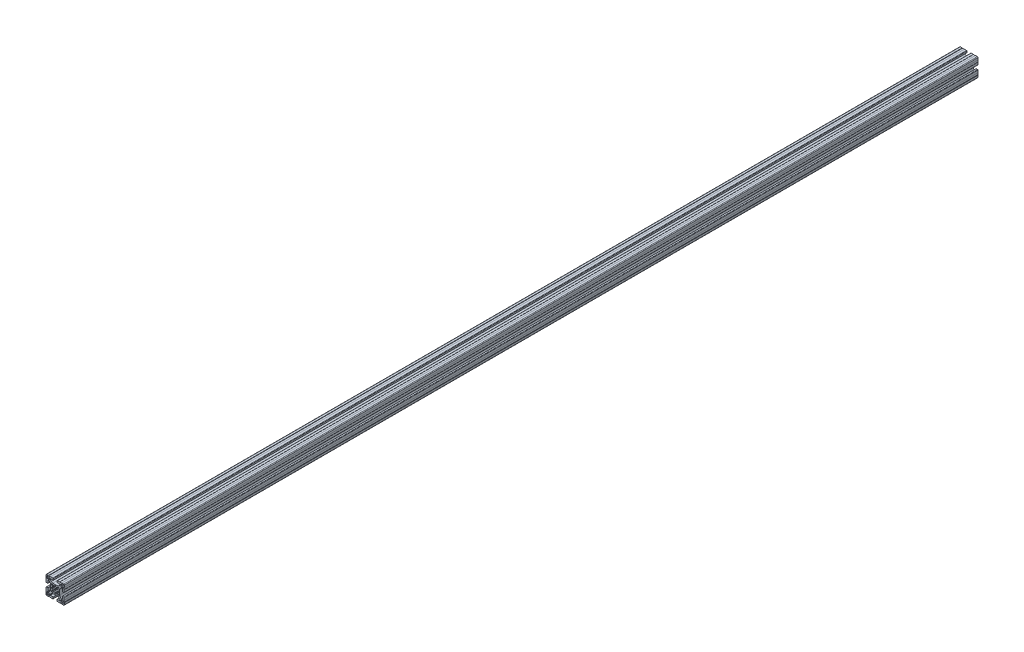
from build123d import *

# Parameters (mm, degrees)
RESSALTO_EXTRUS_O1_DEPTH = 1000


with BuildPart() as part:
    # Esboço1 → Ressalto-extrusão1 (new body, symmetric)
    with BuildSketch(Plane.XY):
        with BuildLine():
            Line((4.14998475, -18.79998475), (4.14998475, -15.899980918))
            ThreePointArc((4.14998475, -15.899980918), (4.179274222, -15.829270089), (4.249985176, -15.799980918))
            Line((4.249985176, -15.799980918), (10.499997871, -15.800007531))
            ThreePointArc((10.499997871, -15.800007531), (10.853552638, -15.653561674), (11, -15.300007531))
            Line((11, -15.300007531), (11, -14.449747468))
            ThreePointArc((11, -14.449747468), (10.885819299, -13.87572232), (10.560660172, -13.389087297))
            Line((10.560660172, -13.389087297), (8.636038969, -11.464466094))
            ThreePointArc((8.636038969, -11.464466094), (7.013922225, -10.380602337), (5.100505063, -10))
            Line((5.100505063, -10), (0, -10))
            Line((0, -10), (-5.100505063, -10))
            ThreePointArc((-5.100505063, -10), (-7.013922225, -10.380602337), (-8.636038969, -11.464466094))
            Line((-8.636038969, -11.464466094), (-10.560660172, -13.389087297))
            ThreePointArc((-10.560660172, -13.389087297), (-10.885819299, -13.87572232), (-11, -14.449747468))
            Line((-11, -14.449747468), (-11, -15.300007531))
            ThreePointArc((-11, -15.300007531), (-10.853552638, -15.653561674), (-10.499997871, -15.800007531))
            Line((-10.499997871, -15.800007531), (-4.249985176, -15.799980918))
            ThreePointArc((-4.249985176, -15.799980918), (-4.179274222, -15.829270089), (-4.14998475, -15.899980918))
            Line((-4.14998475, -15.899980918), (-4.14998475, -18.79998475))
            ThreePointArc((-4.14998475, -18.79998475), (-4.442876463, -19.507090026), (-5.149980492, -19.79998475))
            Line((-5.149980492, -19.79998475), (-9.79996495, -19.80000455))
            Line((-9.79996495, -19.80000455), (-9.99998475, -19.59998475))
            Line((-9.99998475, -19.59998475), (-13.99998475, -19.59998475))
            Line((-13.99998475, -19.59998475), (-14.40000475, -20.00000475))
            Line((-14.40000475, -20.00000475), (-18.50000475, -20.00000475))
            ThreePointArc((-18.50000475, -20.00000475), (-19.560664922, -19.560664922), (-20.00000475, -18.50000475))
            Line((-20.00000475, -18.50000475), (-20.00000475, -14.40000475))
            Line((-20.00000475, -14.40000475), (-19.59998475, -13.99998475))
            Line((-19.59998475, -13.99998475), (-19.59998475, -9.99998475))
            Line((-19.59998475, -9.99998475), (-19.800004551, -9.799964949))
            Line((-19.800004551, -9.799964949), (-19.799984751, -5.149980488))
            ThreePointArc((-19.799984751, -5.149980488), (-19.507090026, -4.442876459), (-18.79998475, -4.149984746))
            Line((-18.79998475, -4.149984746), (-15.899980918, -4.149984746))
            ThreePointArc((-15.899980918, -4.149984746), (-15.829270089, -4.179274218), (-15.799980918, -4.249985172))
            Line((-15.799980918, -4.249985172), (-15.800007532, -10.499997871))
            ThreePointArc((-15.800007532, -10.499997871), (-15.653561675, -10.853552638), (-15.300007532, -11))
            Line((-15.300007532, -11), (-14.449747468, -11))
            ThreePointArc((-14.449747468, -11), (-13.87572232, -10.885819298), (-13.389087297, -10.560660171))
            Line((-13.389087297, -10.560660171), (-11.464466094, -8.636038969))
            ThreePointArc((-11.464466094, -8.636038969), (-10.380602337, -7.013922225), (-10, -5.100505063))
            Line((-10, -5.100505063), (-10, 0))
            Line((-10, 0), (-10, 5.100505064))
            ThreePointArc((-10, 5.100505064), (-10.380602337, 7.013922225), (-11.464466094, 8.63603897))
            Line((-11.464466094, 8.63603897), (-13.389087297, 10.560660172))
            ThreePointArc((-13.389087297, 10.560660172), (-13.87572232, 10.885819299), (-14.449747468, 11))
            Line((-14.449747468, 11), (-15.300007532, 11))
            ThreePointArc((-15.300007532, 11), (-15.653561675, 10.853552638), (-15.800007532, 10.499997871))
            Line((-15.800007532, 10.499997871), (-15.799980918, 4.249985172))
            ThreePointArc((-15.799980918, 4.249985172), (-15.829270089, 4.179274219), (-15.899980918, 4.149984747))
            Line((-15.899980918, 4.149984747), (-18.79998475, 4.149984747))
            ThreePointArc((-18.79998475, 4.149984747), (-19.507090026, 4.44287646), (-19.799984751, 5.149980488))
            Line((-19.799984751, 5.149980488), (-19.800004551, 9.79996495))
            Line((-19.800004551, 9.79996495), (-19.59998475, 9.999984751))
            Line((-19.59998475, 9.999984751), (-19.59998475, 13.999984751))
            Line((-19.59998475, 13.999984751), (-20.00000475, 14.400004751))
            Line((-20.00000475, 14.400004751), (-20.00000475, 18.500004751))
            ThreePointArc((-20.00000475, 18.500004751), (-19.560664922, 19.560664922), (-18.50000475, 20.000004751))
            Line((-18.50000475, 20.000004751), (-14.40000475, 20.000004751))
            Line((-14.40000475, 20.000004751), (-13.99998475, 19.599984751))
            Line((-13.99998475, 19.599984751), (-9.99998475, 19.599984751))
            Line((-9.99998475, 19.599984751), (-9.79996495, 19.800004551))
            Line((-9.79996495, 19.800004551), (-5.149980492, 19.799984751))
            ThreePointArc((-5.149980492, 19.799984751), (-4.442876463, 19.507090026), (-4.14998475, 18.799984751))
            Line((-4.14998475, 18.799984751), (-4.14998475, 15.899980918))
            ThreePointArc((-4.14998475, 15.899980918), (-4.179274222, 15.82927009), (-4.249985176, 15.799980918))
            Line((-4.249985176, 15.799980918), (-10.499997871, 15.800007531))
            ThreePointArc((-10.499997871, 15.800007531), (-10.853552638, 15.653561675), (-11, 15.300007531))
            Line((-11, 15.300007531), (-11, 14.449747469))
            ThreePointArc((-11, 14.449747469), (-10.885819299, 13.87572232), (-10.560660172, 13.389087297))
            Line((-10.560660172, 13.389087297), (-8.636038969, 11.464466095))
            ThreePointArc((-8.636038969, 11.464466095), (-7.013922225, 10.380602338), (-5.100505063, 10.000000001))
            Line((-5.100505063, 10.000000001), (0, 10.000000001))
            Line((0, 10.000000001), (5.100505063, 10.000000001))
            ThreePointArc((5.100505063, 10.000000001), (7.013922225, 10.380602338), (8.636038969, 11.464466095))
            Line((8.636038969, 11.464466095), (10.560660172, 13.389087297))
            ThreePointArc((10.560660172, 13.389087297), (10.885819299, 13.87572232), (11, 14.449747469))
            Line((11, 14.449747469), (11, 15.300007531))
            ThreePointArc((11, 15.300007531), (10.853552638, 15.653561675), (10.499997871, 15.800007531))
            Line((10.499997871, 15.800007531), (4.249985176, 15.799980918))
            ThreePointArc((4.249985176, 15.799980918), (4.179274222, 15.82927009), (4.14998475, 15.899980918))
            Line((4.14998475, 15.899980918), (4.14998475, 18.799984751))
            ThreePointArc((4.14998475, 18.799984751), (4.442876463, 19.507090026), (5.149980492, 19.799984751))
            Line((5.149980492, 19.799984751), (9.79996495, 19.800004551))
            Line((9.79996495, 19.800004551), (9.99998475, 19.599984751))
            Line((9.99998475, 19.599984751), (13.99998475, 19.599984751))
            Line((13.99998475, 19.599984751), (14.40000475, 20.000004751))
            Line((14.40000475, 20.000004751), (18.50000475, 20.000004751))
            ThreePointArc((18.50000475, 20.000004751), (19.560664922, 19.560664922), (20.00000475, 18.500004751))
            Line((20.00000475, 18.500004751), (20.00000475, 14.400004751))
            Line((20.00000475, 14.400004751), (19.59998475, 13.999984751))
            Line((19.59998475, 13.999984751), (19.59998475, 9.999984751))
            Line((19.59998475, 9.999984751), (19.800004551, 9.79996495))
            Line((19.800004551, 9.79996495), (19.799984751, 5.149980488))
            ThreePointArc((19.799984751, 5.149980488), (19.507090026, 4.44287646), (18.79998475, 4.149984747))
            Line((18.79998475, 4.149984747), (15.899980918, 4.149984747))
            ThreePointArc((15.899980918, 4.149984747), (15.829270089, 4.179274219), (15.799980918, 4.249985172))
            Line((15.799980918, 4.249985172), (15.800007532, 10.499997871))
            ThreePointArc((15.800007532, 10.499997871), (15.653561675, 10.853552638), (15.300007532, 11))
            Line((15.300007532, 11), (14.449747468, 11))
            ThreePointArc((14.449747468, 11), (13.87572232, 10.885819299), (13.389087297, 10.560660172))
            Line((13.389087297, 10.560660172), (11.464466094, 8.63603897))
            ThreePointArc((11.464466094, 8.63603897), (10.380602337, 7.013922225), (10, 5.100505064))
            Line((10, 5.100505064), (10, 0))
            Line((10, 0), (10, -5.100505063))
            ThreePointArc((10, -5.100505063), (10.380602337, -7.013922225), (11.464466094, -8.636038969))
            Line((11.464466094, -8.636038969), (13.389087297, -10.560660171))
            ThreePointArc((13.389087297, -10.560660171), (13.87572232, -10.885819298), (14.449747468, -11))
            Line((14.449747468, -11), (15.300007532, -11))
            ThreePointArc((15.300007532, -11), (15.653561675, -10.853552638), (15.800007532, -10.499997871))
            Line((15.800007532, -10.499997871), (15.799980918, -4.249985172))
            ThreePointArc((15.799980918, -4.249985172), (15.829270089, -4.179274218), (15.899980918, -4.149984746))
            Line((15.899980918, -4.149984746), (18.79998475, -4.149984746))
            ThreePointArc((18.79998475, -4.149984746), (19.507090026, -4.442876459), (19.799984751, -5.149980488))
            Line((19.799984751, -5.149980488), (19.800004551, -9.799964949))
            Line((19.800004551, -9.799964949), (19.59998475, -9.99998475))
            Line((19.59998475, -9.99998475), (19.59998475, -13.99998475))
            Line((19.59998475, -13.99998475), (20.00000475, -14.40000475))
            Line((20.00000475, -14.40000475), (20.00000475, -18.50000475))
            ThreePointArc((20.00000475, -18.50000475), (19.560664922, -19.560664922), (18.50000475, -20.00000475))
            Line((18.50000475, -20.00000475), (14.40000475, -20.00000475))
            Line((14.40000475, -20.00000475), (13.99998475, -19.59998475))
            Line((13.99998475, -19.59998475), (9.99998475, -19.59998475))
            Line((9.99998475, -19.59998475), (9.79996495, -19.80000455))
            Line((9.79996495, -19.80000455), (5.149980492, -19.79998475))
            ThreePointArc((5.149980492, -19.79998475), (4.442876463, -19.507090026), (4.14998475, -18.79998475))
        make_face()
        with BuildLine():
            Line((-17.857240871, 16.796580699), (-17.416672281, 16.356012109))
            ThreePointArc((-17.416672281, 16.356012109), (-17.7, 15.2), (-17.416672281, 14.04398789))
            Line((-17.416672281, 14.04398789), (-17.857240871, 13.603419301))
            ThreePointArc((-17.857240871, 13.603419301), (-17.857240871, 12.542759129), (-16.796580699, 12.542759129))
            Line((-16.796580699, 12.542759129), (-16.35601211, 12.983327719))
            ThreePointArc((-16.35601211, 12.983327719), (-15.2, 12.7), (-14.04398789, 12.983327719))
            Line((-14.04398789, 12.983327719), (-13.603419301, 12.542759129))
            ThreePointArc((-13.603419301, 12.542759129), (-12.542759129, 12.542759129), (-12.542759129, 13.603419301))
            Line((-12.542759129, 13.603419301), (-12.983327719, 14.04398789))
            ThreePointArc((-12.983327719, 14.04398789), (-12.7, 15.2), (-12.983327719, 16.356012109))
            Line((-12.983327719, 16.356012109), (-12.542759081, 16.796580747))
            ThreePointArc((-12.542759081, 16.796580747), (-12.542759081, 17.857240919), (-13.603419253, 17.857240919))
            Line((-13.603419253, 17.857240919), (-14.04398789, 17.416672281))
            ThreePointArc((-14.04398789, 17.416672281), (-15.2, 17.7), (-16.35601211, 17.416672281))
            Line((-16.35601211, 17.416672281), (-16.796580699, 17.857240871))
            ThreePointArc((-16.796580699, 17.857240871), (-17.857240871, 17.857240871), (-17.857240871, 16.796580699))
        make_face(mode=Mode.SUBTRACT)
        with BuildLine():
            Line((17.416672281, 14.04398789), (17.857240871, 13.603419301))
            ThreePointArc((17.857240871, 13.603419301), (17.857240871, 12.542759129), (16.796580699, 12.542759129))
            Line((16.796580699, 12.542759129), (16.35601211, 12.983327719))
            ThreePointArc((16.35601211, 12.983327719), (15.2, 12.7), (14.043987891, 12.983327719))
            Line((14.043987891, 12.983327719), (13.603419301, 12.542759129))
            ThreePointArc((13.603419301, 12.542759129), (12.542759129, 12.542759129), (12.542759129, 13.603419301))
            Line((12.542759129, 13.603419301), (12.983327719, 14.04398789))
            ThreePointArc((12.983327719, 14.04398789), (12.7, 15.2), (12.983327719, 16.356012109))
            Line((12.983327719, 16.356012109), (12.542759081, 16.796580747))
            ThreePointArc((12.542759081, 16.796580747), (12.542759081, 17.857240919), (13.603419253, 17.857240919))
            Line((13.603419253, 17.857240919), (14.043987891, 17.416672281))
            ThreePointArc((14.043987891, 17.416672281), (15.2, 17.7), (16.35601211, 17.416672281))
            Line((16.35601211, 17.416672281), (16.796580699, 17.857240871))
            ThreePointArc((16.796580699, 17.857240871), (17.857240871, 17.857240871), (17.857240871, 16.796580699))
            Line((17.857240871, 16.796580699), (17.416672281, 16.356012109))
            ThreePointArc((17.416672281, 16.356012109), (17.7, 15.2), (17.416672281, 14.04398789))
        make_face(mode=Mode.SUBTRACT)
        with BuildLine():
            Line((-17.416672281, -14.04398789), (-17.857240871, -13.603419301))
            ThreePointArc((-17.857240871, -13.603419301), (-17.857240871, -12.542759129), (-16.796580699, -12.542759129))
            Line((-16.796580699, -12.542759129), (-16.35601211, -12.983327719))
            ThreePointArc((-16.35601211, -12.983327719), (-15.2, -12.7), (-14.04398789, -12.983327719))
            Line((-14.04398789, -12.983327719), (-13.603419301, -12.542759129))
            ThreePointArc((-13.603419301, -12.542759129), (-12.542759129, -12.542759129), (-12.542759129, -13.603419301))
            Line((-12.542759129, -13.603419301), (-12.983327719, -14.04398789))
            ThreePointArc((-12.983327719, -14.04398789), (-12.7, -15.2), (-12.983327719, -16.35601211))
            Line((-12.983327719, -16.35601211), (-12.542759081, -16.796580747))
            ThreePointArc((-12.542759081, -16.796580747), (-12.542759081, -17.857240919), (-13.603419253, -17.857240919))
            Line((-13.603419253, -17.857240919), (-14.04398789, -17.416672281))
            ThreePointArc((-14.04398789, -17.416672281), (-15.2, -17.7), (-16.35601211, -17.416672281))
            Line((-16.35601211, -17.416672281), (-16.796580699, -17.857240871))
            ThreePointArc((-16.796580699, -17.857240871), (-17.857240871, -17.857240871), (-17.857240871, -16.796580699))
            Line((-17.857240871, -16.796580699), (-17.416672281, -16.35601211))
            ThreePointArc((-17.416672281, -16.35601211), (-17.7, -15.2), (-17.416672281, -14.04398789))
        make_face(mode=Mode.SUBTRACT)
        with BuildLine():
            Line((17.857240871, -16.796580699), (17.416672281, -16.35601211))
            ThreePointArc((17.416672281, -16.35601211), (17.7, -15.2), (17.416672281, -14.04398789))
            Line((17.416672281, -14.04398789), (17.857240871, -13.603419301))
            ThreePointArc((17.857240871, -13.603419301), (17.857240871, -12.542759129), (16.796580699, -12.542759129))
            Line((16.796580699, -12.542759129), (16.35601211, -12.983327719))
            ThreePointArc((16.35601211, -12.983327719), (15.2, -12.7), (14.043987891, -12.983327719))
            Line((14.043987891, -12.983327719), (13.603419301, -12.542759129))
            ThreePointArc((13.603419301, -12.542759129), (12.542759129, -12.542759129), (12.542759129, -13.603419301))
            Line((12.542759129, -13.603419301), (12.983327719, -14.04398789))
            ThreePointArc((12.983327719, -14.04398789), (12.7, -15.2), (12.983327719, -16.35601211))
            Line((12.983327719, -16.35601211), (12.542759081, -16.796580747))
            ThreePointArc((12.542759081, -16.796580747), (12.542759081, -17.857240919), (13.603419253, -17.857240919))
            Line((13.603419253, -17.857240919), (14.043987891, -17.416672281))
            ThreePointArc((14.043987891, -17.416672281), (15.2, -17.7), (16.35601211, -17.416672281))
            Line((16.35601211, -17.416672281), (16.796580699, -17.857240871))
            ThreePointArc((16.796580699, -17.857240871), (17.857240871, -17.857240871), (17.857240871, -16.796580699))
        make_face(mode=Mode.SUBTRACT)
        with BuildLine():
            Line((-5.31389005, -7.63550963), (-7.648765071, -8.261137506))
            ThreePointArc((-7.648765071, -8.261137506), (-8.131727984, -8.131727984), (-8.261137506, -7.64876507))
            Line((-8.261137506, -7.64876507), (-7.63550963, -5.313890049))
            ThreePointArc((-7.63550963, -5.313890049), (-7.568281523, -5.165514456), (-7.456927431, -5.046622902))
            Line((-7.456927431, -5.046622902), (-5.743958929, -3.73221594))
            ThreePointArc((-5.743958929, -3.73221594), (-6.328574798, -2.621381512), (-6.70066751, -1.422517109))
            Line((-6.70066751, -1.422517109), (-7.520425705, -1.314593895))
            ThreePointArc((-7.520425705, -1.314593895), (-7.812495975, -1.168604027), (-7.952173449, -0.873462896))
            ThreePointArc((-7.952173449, -0.873462896), (-8, 0), (-7.952173449, 0.873462896))
            ThreePointArc((-7.952173449, 0.873462896), (-7.812495975, 1.168604027), (-7.520425705, 1.314593895))
            Line((-7.520425705, 1.314593895), (-6.70066751, 1.422517109))
            ThreePointArc((-6.70066751, 1.422517109), (-6.328574798, 2.621381512), (-5.743958929, 3.73221594))
            Line((-5.743958929, 3.73221594), (-7.456927431, 5.046622902))
            ThreePointArc((-7.456927431, 5.046622902), (-7.568281523, 5.165514456), (-7.63550963, 5.313890049))
            Line((-7.63550963, 5.313890049), (-8.261137506, 7.64876507))
            ThreePointArc((-8.261137506, 7.64876507), (-8.131727984, 8.131727984), (-7.648765071, 8.261137506))
            Line((-7.648765071, 8.261137506), (-5.31389005, 7.63550963))
            ThreePointArc((-5.31389005, 7.63550963), (-5.165514456, 7.568281523), (-5.046622902, 7.456927431))
            Line((-5.046622902, 7.456927431), (-3.73221594, 5.743958929))
            ThreePointArc((-3.73221594, 5.743958929), (-2.621381512, 6.328574798), (-1.422517109, 6.70066751))
            Line((-1.422517109, 6.70066751), (-1.314593895, 7.520425705))
            ThreePointArc((-1.314593895, 7.520425705), (-1.168604027, 7.812495975), (-0.873462896, 7.952173449))
            ThreePointArc((-0.873462896, 7.952173449), (0, 8), (0.873462896, 7.952173449))
            ThreePointArc((0.873462896, 7.952173449), (1.168604027, 7.812495975), (1.314593895, 7.520425705))
            Line((1.314593895, 7.520425705), (1.422517109, 6.70066751))
            ThreePointArc((1.422517109, 6.70066751), (2.621381512, 6.328574798), (3.73221594, 5.743958929))
            Line((3.73221594, 5.743958929), (5.046622902, 7.456927431))
            ThreePointArc((5.046622902, 7.456927431), (5.165514456, 7.568281523), (5.31389005, 7.63550963))
            Line((5.31389005, 7.63550963), (7.648765071, 8.261137506))
            ThreePointArc((7.648765071, 8.261137506), (8.131727984, 8.131727984), (8.261137506, 7.64876507))
            Line((8.261137506, 7.64876507), (7.63550963, 5.313890049))
            ThreePointArc((7.63550963, 5.313890049), (7.568281523, 5.165514456), (7.456927431, 5.046622902))
            Line((7.456927431, 5.046622902), (5.743958929, 3.73221594))
            ThreePointArc((5.743958929, 3.73221594), (6.328574798, 2.621381512), (6.70066751, 1.422517109))
            Line((6.70066751, 1.422517109), (7.520425705, 1.314593895))
            ThreePointArc((7.520425705, 1.314593895), (7.812495975, 1.168604027), (7.952173449, 0.873462896))
            ThreePointArc((7.952173449, 0.873462896), (8, 0), (7.952173449, -0.873462896))
            ThreePointArc((7.952173449, -0.873462896), (7.812495975, -1.168604027), (7.520425705, -1.314593895))
            Line((7.520425705, -1.314593895), (6.70066751, -1.422517109))
            ThreePointArc((6.70066751, -1.422517109), (6.328574798, -2.621381512), (5.743958929, -3.73221594))
            Line((5.743958929, -3.73221594), (7.456927431, -5.046622902))
            ThreePointArc((7.456927431, -5.046622902), (7.568281523, -5.165514456), (7.63550963, -5.313890049))
            Line((7.63550963, -5.313890049), (8.261137506, -7.64876507))
            ThreePointArc((8.261137506, -7.64876507), (8.131727984, -8.131727984), (7.648765071, -8.261137506))
            Line((7.648765071, -8.261137506), (5.31389005, -7.63550963))
            ThreePointArc((5.31389005, -7.63550963), (5.165514456, -7.568281523), (5.046622902, -7.456927431))
            Line((5.046622902, -7.456927431), (3.73221594, -5.743958929))
            ThreePointArc((3.73221594, -5.743958929), (2.621381512, -6.328574798), (1.422517109, -6.70066751))
            Line((1.422517109, -6.70066751), (1.314593895, -7.520425705))
            ThreePointArc((1.314593895, -7.520425705), (1.168604027, -7.812495975), (0.873462896, -7.952173449))
            ThreePointArc((0.873462896, -7.952173449), (0, -8), (-0.873462896, -7.952173449))
            ThreePointArc((-0.873462896, -7.952173449), (-1.168604027, -7.812495975), (-1.314593895, -7.520425705))
            Line((-1.314593895, -7.520425705), (-1.422517109, -6.70066751))
            ThreePointArc((-1.422517109, -6.70066751), (-2.621381512, -6.328574798), (-3.73221594, -5.743958929))
            Line((-3.73221594, -5.743958929), (-5.046622902, -7.456927431))
            ThreePointArc((-5.046622902, -7.456927431), (-5.165514456, -7.568281523), (-5.31389005, -7.63550963))
        make_face(mode=Mode.SUBTRACT)
    extrude(amount=RESSALTO_EXTRUS_O1_DEPTH, both=True)


solid = part.part
